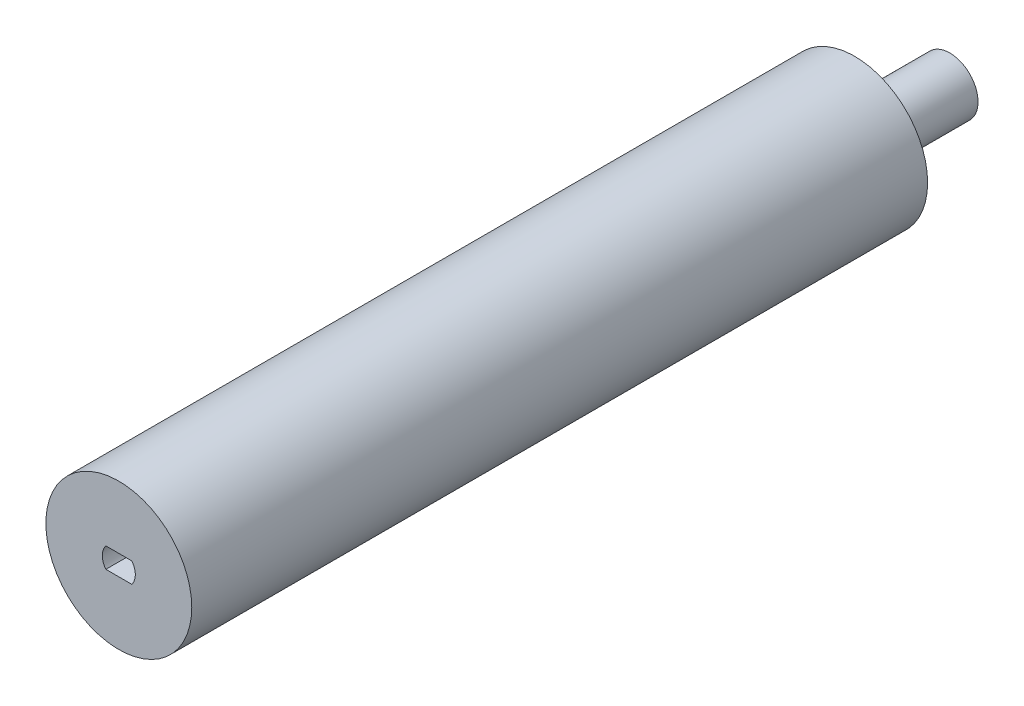
from build123d import *

# Parameters (mm, degrees)
SKETCH2_R           = 11.5
BOSS_EXTRUDE1_DEPTH = 116
SKETCH3_R           = 4.45
BOSS_EXTRUDE2_DEPTH = 15
CUT_EXTRUDE1_DEPTH  = 10


with BuildPart() as part:
    # Sketch2 → Boss-Extrude1 (new body)
    with BuildSketch(Plane.XY):
        Circle(SKETCH2_R)
    extrude(amount=-BOSS_EXTRUDE1_DEPTH)

    # Sketch3 → Boss-Extrude2 (add)
    with BuildSketch(Plane(origin=(0, 0, -116), x_dir=(-1, 0, 0), z_dir=(0, 0, -1))):
        Circle(SKETCH3_R)
    extrude(amount=BOSS_EXTRUDE2_DEPTH)

    # Sketch1 → Cut-Extrude1 (cut)
    with BuildSketch(Plane.XY):
        with BuildLine():
            Line((2.051104302, -1.567413373), (-2.047676004, -1.567413373))
            ThreePointArc((-2.047676004, -1.567413373), (-2.598285851, 0.032586627), (-2.047676004, 1.632586627))
            Line((-2.047676004, 1.632586627), (2.051104302, 1.632586627))
            ThreePointArc((2.051104302, 1.632586627), (2.601714149, 0.032586627), (2.051104302, -1.567413373))
        make_face()
    extrude(amount=-CUT_EXTRUDE1_DEPTH, mode=Mode.SUBTRACT)


solid = part.part
